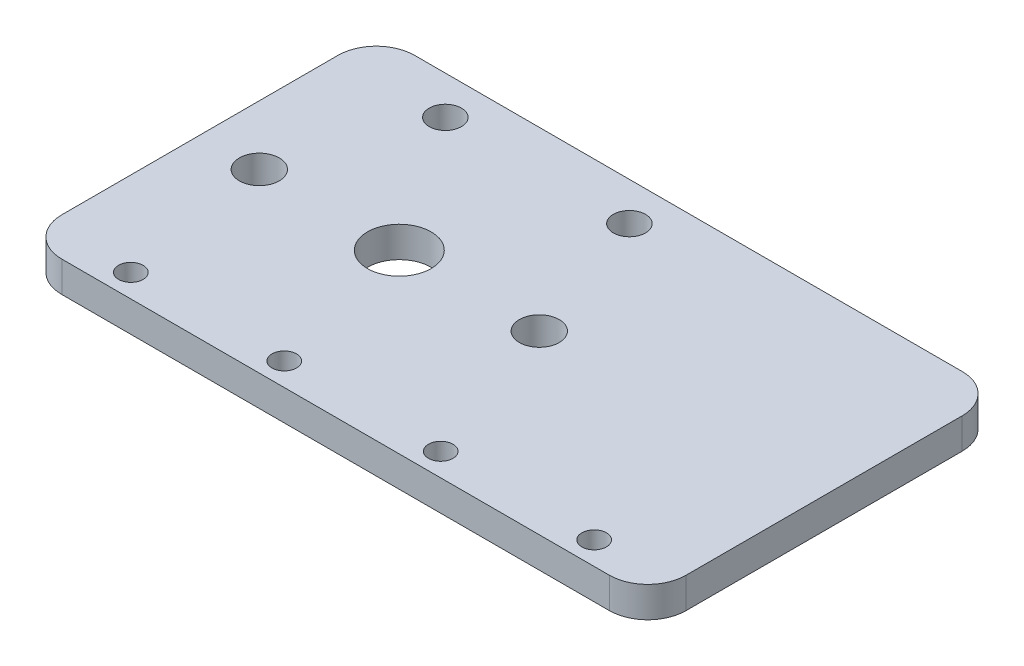
from build123d import *

# Parameters (mm, degrees)
SKETCH_1_W            = 52
SKETCH_1_H            = 46
SKETCH_1_R            = 2.6
SKETCH_1_R_2          = 4.15
EXTRUDE_436_DEPTH     = 4
SKETCH_4_R            = 2.1
CUT_EXTRUDE_686_DEPTH = 5
SKETCH_6_R            = 2.1
EXTRUDE_1_DEPTH       = 4
SKETCH_7_R            = 1.2
CUT_EXTRUDE_1_DEPTH   = 5
SKETCH_8_W            = 29.384652785
SKETCH_8_H            = 46
EXTRUDE_2_DEPTH       = 4
FILLET_1_R            = 5
SKETCH_9_R            = 1.6
CUT_EXTRUDE_2_DEPTH   = 5


with BuildPart() as part:
    # 草图1 → Extrude 436 (new body)
    with BuildSketch(Plane(origin=(0, 0, 0), x_dir=(1, 0, 0), z_dir=(0, 1, 0))):
        Rectangle(SKETCH_1_W, SKETCH_1_H)
        with Locations((-18.25, 0)):
            Circle(SKETCH_1_R, mode=Mode.SUBTRACT)
        with Locations((18.25, 0)):
            Circle(SKETCH_1_R, mode=Mode.SUBTRACT)
        Circle(SKETCH_1_R_2, mode=Mode.SUBTRACT)
    extrude(amount=EXTRUDE_436_DEPTH)

    # 草图4 → Cut-Extrude 686 (cut, through all)
    with BuildSketch(Plane(origin=(0, 4, 0), x_dir=(1, 0, 0), z_dir=(0, 1, 0))):
        with Locations((-12, 18)):
            Circle(SKETCH_4_R)
        with Locations((12, 18)):
            Circle(SKETCH_4_R)
        with Locations((12, -18)):
            Circle(SKETCH_4_R)
        with Locations((-12, -18)):
            Circle(SKETCH_4_R)
    extrude(amount=-CUT_EXTRUDE_686_DEPTH, mode=Mode.SUBTRACT)

    # 草图6 → 凸台-拉伸1 (add)
    with BuildSketch(Plane(origin=(0, 4, 0), x_dir=(1, 0, 0), z_dir=(0, 1, 0))):
        with Locations((-12, -18)):
            Circle(SKETCH_6_R)
        with Locations((12, -18)):
            Circle(SKETCH_6_R)
    extrude(amount=-EXTRUDE_1_DEPTH)

    # 草图7 → 切除-拉伸1 (cut, through all)
    with BuildSketch(Plane(origin=(0, 4, 0), x_dir=(1, 0, 0), z_dir=(0, 1, 0))):
        with Locations((5, -20)):
            Circle(SKETCH_7_R)
        with Locations((-15, -20)):
            Circle(SKETCH_7_R)
    extrude(amount=-CUT_EXTRUDE_1_DEPTH, mode=Mode.SUBTRACT)

    # 草图8 → 凸台-拉伸2 (add)
    with BuildSketch(Plane.XZ):
        with Locations((40.692326393, 0)):
            Rectangle(SKETCH_8_W, SKETCH_8_H)
    extrude(amount=-EXTRUDE_2_DEPTH)

    # 圆角1
    fillet_1_edges = [part.edges().sort_by_distance(p)[0] for p in [
        (55.384652785, 2, 23),
        (55.384652785, 2, -23),
        (-26, 2, 23),
        (-26, 2, -23),
    ]]
    fillet(fillet_1_edges, radius=FILLET_1_R)

    # 草图9 → 切除-拉伸2 (cut, through all)
    with BuildSketch(Plane.XZ):
        with Locations((-15, 20)):
            Circle(SKETCH_9_R)
        with Locations((5, 20)):
            Circle(SKETCH_9_R)
        with Locations((25.4, 20)):
            Circle(SKETCH_9_R)
        with Locations((45.4, 20)):
            Circle(SKETCH_9_R)
    extrude(amount=-CUT_EXTRUDE_2_DEPTH, mode=Mode.SUBTRACT)


solid = part.part
